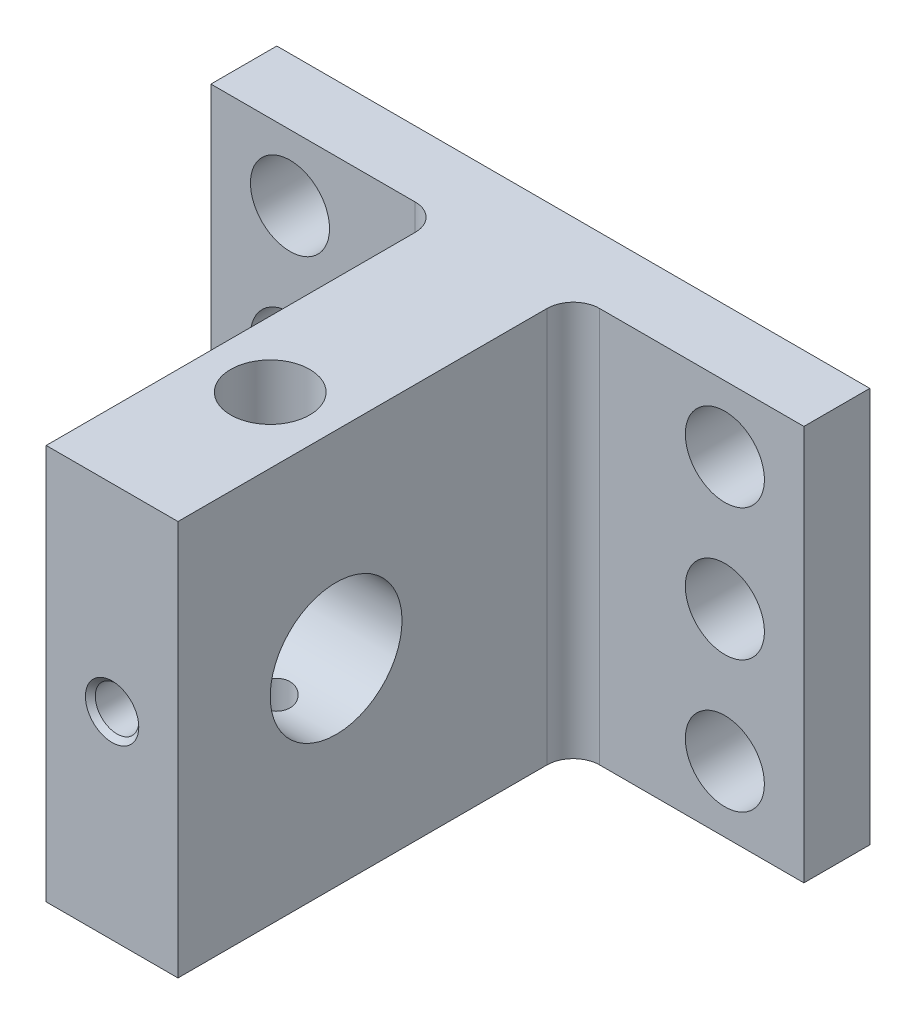
from build123d import *

# Parameters (mm, degrees)
SKETCH1_W                   = 45
SKETCH1_H                   = 30
BASE_DEPTH                  = 5
SKETCH2_W                   = 10
SKETCH2_H                   = 30
BOSS_EXTRUDE2_DEPTH         = 30
SKETCH3_R                   = 5
CUT_EXTRUDE3_DEPTH          = 10
SKETCH9_R                   = 3
SCREW_DEPTH                 = 5
SKETCH10_R                  = 3
TOP_HOLE_DEPTH              = 15
SKETCH11_R                  = 1.5
BOTTOM_HOLE_DEPTH           = 15
FILLET1_R                   = 2
FILLET2_R                   = 2
M4_TAPPED_HOLE3_D           = 3.3
M4_TAPPED_HOLE3_DEPTH       = 10.1
M4_TAPPED_HOLE3_CSINK_D     = 4.05
M4_TAPPED_HOLE3_CSINK_ANGLE = 90
M4_TAPPED_HOLE3_TIP         = 0.991420021


with BuildPart() as part:
    # Sketch1 → Base (new body)
    with BuildSketch(Plane.XY):
        Rectangle(SKETCH1_W, SKETCH1_H)
    extrude(amount=BASE_DEPTH)

    # Sketch2 → Boss-Extrude2 (add)
    with BuildSketch(Plane.XY.offset(5)):
        Rectangle(SKETCH2_W, SKETCH2_H)
    extrude(amount=BOSS_EXTRUDE2_DEPTH)

    # Sketch3 → Cut-Extrude3 (cut)
    with BuildSketch(Plane.ZY.offset(5)):
        with Locations((23, 0)):
            Circle(SKETCH3_R)
    extrude(amount=-CUT_EXTRUDE3_DEPTH, mode=Mode.SUBTRACT)

    # Sketch9 → Screw (cut)
    with BuildSketch(Plane.XY.offset(5)):
        with Locations((-16.5, 10)):
            Circle(SKETCH9_R)
        with Locations((-16.5, 0)):
            Circle(SKETCH9_R)
        with Locations((-16.5, -10)):
            Circle(SKETCH9_R)
        with Locations((16.5, -10)):
            Circle(SKETCH9_R)
        with Locations((16.5, 0)):
            Circle(SKETCH9_R)
        with Locations((16.5, 10)):
            Circle(SKETCH9_R)
    extrude(amount=-SCREW_DEPTH, mode=Mode.SUBTRACT)

    # Sketch10 → Top hole (cut)
    with BuildSketch(Plane(origin=(0, 15, 0), x_dir=(1, 0, 0), z_dir=(0, 1, 0))):
        with Locations((0, -23)):
            Circle(SKETCH10_R)
    extrude(amount=-TOP_HOLE_DEPTH, mode=Mode.SUBTRACT)

    # Sketch11 → Bottom hole (cut)
    with BuildSketch(Plane.XZ.offset(15)):
        with Locations((0, 23)):
            Circle(SKETCH11_R)
    extrude(amount=-BOTTOM_HOLE_DEPTH, mode=Mode.SUBTRACT)

    # Fillet1
    fillet1_edges = [part.edges().sort_by_distance(p)[0] for p in [
        (-5, 0, 5),
    ]]
    fillet(fillet1_edges, radius=FILLET1_R)

    # Fillet2
    fillet2_edges = [part.edges().sort_by_distance(p)[0] for p in [
        (5, 0, 5),
    ]]
    fillet(fillet2_edges, radius=FILLET2_R)

    # M4 Tapped Hole3
    with Locations(Plane.XY.offset(35)):
        with Locations((0, 0)):
            CounterSinkHole(M4_TAPPED_HOLE3_D / 2, M4_TAPPED_HOLE3_CSINK_D / 2, depth=M4_TAPPED_HOLE3_DEPTH, counter_sink_angle=M4_TAPPED_HOLE3_CSINK_ANGLE)
            with Locations((0, 0, -(M4_TAPPED_HOLE3_DEPTH + M4_TAPPED_HOLE3_TIP / 2))):  # 118° drill point
                Cone(0, M4_TAPPED_HOLE3_D / 2, M4_TAPPED_HOLE3_TIP, mode=Mode.SUBTRACT)


solid = part.part
